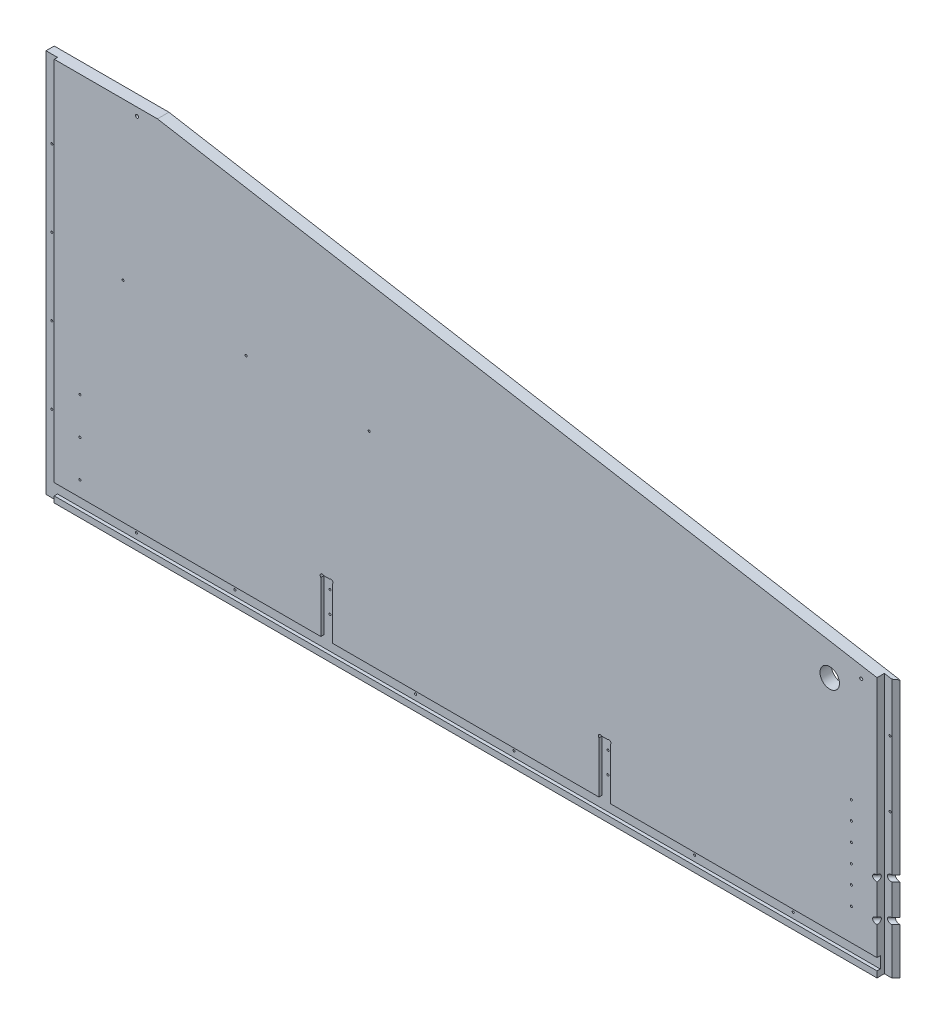
from build123d import *

# Parameters (mm, degrees)
CABSIDERIGHT_THICKNESS_DEPTH  = 17.78
LEDGECUTS_DEPTH_DEPTH         = 5.08
SKETCH9_R                     = 3.301999998
SKETCH9_R_2                   = 3.174999998
SKETCH9_R_3                   = 3.174999999
CUT_EXTRUDE4_DEPTH            = 5.08
SKETCH10_R                    = 15.08125
SKETCH10_R_2                  = 1.5875
CUT_EXTRUDE5_DEPTH            = 17.78
FRONTLEDGECUT_W               = 17.78
FRONTLEDGECUT_H               = 402.324113577
FRONTLEDGECUT_THICKNESS_DEPTH = 11.43
CUT_EXTRUDE8_DEPTH            = 594.36
SKETCH15_R                    = 2.38125
CUT_EXTRUDE9_DEPTH            = 17.78
SKETCH16_R                    = 1.5875
CUT_EXTRUDE10_DEPTH           = 12.7
SKETCH17_R                    = 4.7625
CUT_EXTRUDE11_DEPTH           = 76.2


with BuildPart() as part:
    # CabSideRight_Outline → CabSideRight_Thickness (new body)
    with BuildSketch(Plane.XY):
        Polygon((9092.234544556, -4658.6775), (10222.970833334, -4853.78125), (10222.970833334, -5253.0375), (8914.870833334, -5253.0375), (8914.870833334, -4658.6775), align=None)
    extrude(amount=-CABSIDERIGHT_THICKNESS_DEPTH)

    # CabSideRight_LedgeCuts → LedgeCuts_Depth (cut)
    with BuildSketch(Plane.XY):
        Polygon((8932.650833334, -4658.6775), (8914.870833334, -4658.6775), (8914.870833334, -5253.0375), (8932.650833334, -5253.0375), (8932.650833334, -5243.5125), (10222.970833334, -5243.5125), (10222.970833334, -5225.7325), (9792.864166668, -5225.7325), (9792.864166668, -5141.912499999), (9775.084166668, -5141.912499999), (9775.084166668, -5225.7325), (9362.757500002, -5225.7325), (9362.757500002, -5141.9125), (9344.977500002, -5141.912499999), (9344.977500002, -5225.7325), (8932.650833334, -5225.7325), align=None)
    extrude(amount=-LEDGECUTS_DEPTH_DEPTH, mode=Mode.SUBTRACT)

    # Sketch9 → Cut-Extrude4 (cut)
    with BuildSketch(Plane.XY):
        with Locations((9347.222564031, -5144.157564028)):
            Circle(SKETCH9_R)
        with Locations((9360.512435973, -5144.15756403)):
            Circle(SKETCH9_R_2)
        with Locations((9777.329230699, -5144.157564029)):
            Circle(SKETCH9_R_3)
        with Locations((9790.619102638, -5144.157564029)):
            Circle(SKETCH9_R_3)
    extrude(amount=-CUT_EXTRUDE4_DEPTH, mode=Mode.SUBTRACT)

    # Sketch10 → Cut-Extrude5 (cut)
    with BuildSketch(Plane.XY):
        with Locations((10132.081036572, -4887.549352662)):
            Circle(SKETCH10_R)
        with Locations((10165.516033334, -5148.2625)):
            Circle(SKETCH10_R_2)
        with Locations((8923.760833334, -4778.904166666)):
            Circle(SKETCH10_R_2)
        with Locations((8923.760833334, -4897.4375)):
            Circle(SKETCH10_R_2)
        with Locations((8923.760833334, -5015.970833334)):
            Circle(SKETCH10_R_2)
        with Locations((8923.760833334, -5134.504166666)):
            Circle(SKETCH10_R_2)
        with Locations((9054.570833334, -5234.6225)):
            Circle(SKETCH10_R_2)
        with Locations((9206.970833334, -5234.6225)):
            Circle(SKETCH10_R_2)
        with Locations((9353.8675, -5193.9825)):
            Circle(SKETCH10_R_2)
        with Locations((9353.8675, -5160.9625)):
            Circle(SKETCH10_R_2)
        with Locations((9486.370833334, -5234.6225)):
            Circle(SKETCH10_R_2)
        with Locations((9638.770833334, -5234.6225)):
            Circle(SKETCH10_R_2)
        with Locations((9783.974166666, -5193.9825)):
            Circle(SKETCH10_R_2)
        with Locations((9783.974166666, -5160.9625)):
            Circle(SKETCH10_R_2)
        with Locations((9918.170833334, -5234.6225)):
            Circle(SKETCH10_R_2)
        with Locations((10070.570833334, -5234.6225)):
            Circle(SKETCH10_R_2)
        with Locations((10214.080833334, -5031.58125)):
            Circle(SKETCH10_R_2)
        with Locations((10214.080833334, -4929.98125)):
            Circle(SKETCH10_R_2)
        with Locations((10165.516033334, -5091.1125)):
            Circle(SKETCH10_R_2)
        with Locations((8972.338333334, -5087.9375)):
            Circle(SKETCH10_R_2)
        with Locations((8972.338333334, -5145.0875)):
            Circle(SKETCH10_R_2)
        with Locations((8972.338333334, -5202.2375)):
            Circle(SKETCH10_R_2)
        with Locations((10165.503333334, -5176.8375)):
            Circle(SKETCH10_R_2)
        with Locations((10165.503333334, -5119.6875)):
            Circle(SKETCH10_R_2)
        with Locations((10165.503333334, -5062.5375)):
            Circle(SKETCH10_R_2)
        with Locations((10165.516033334, -5033.9625)):
            Circle(SKETCH10_R_2)
    extrude(amount=-CUT_EXTRUDE5_DEPTH, mode=Mode.SUBTRACT)

    # FrontLedgeCut → FrontLedgeCut_Thickness (cut)
    with BuildSketch(Plane.XY):
        with Locations((10214.080833334, -5051.875443212)):
            Rectangle(FRONTLEDGECUT_W, FRONTLEDGECUT_H)
    extrude(amount=-FRONTLEDGECUT_THICKNESS_DEPTH, mode=Mode.SUBTRACT)

    # FrontBevelAngleCut → Cut-Extrude8 (cut)
    with BuildSketch(Plane.XZ.offset(5253.0375)):
        Polygon((10222.970833334, -11.43), (10229.320833334, -11.43), (10222.970833334, -17.78), (10216.620833334, -11.43), align=None)
    extrude(amount=-CUT_EXTRUDE8_DEPTH, mode=Mode.SUBTRACT)

    # Sketch15 → Cut-Extrude9 (cut)
    with BuildSketch(Plane(origin=(0, 0, -17.78), x_dir=(-1, 0, 0), z_dir=(0, 0, -1))):
        with Locations((-10180.810459726, -4864.401180469)):
            Circle(SKETCH15_R)
        with Locations((-9060.71197776, -4671.132938908)):
            Circle(SKETCH15_R)
    extrude(amount=-CUT_EXTRUDE9_DEPTH, mode=Mode.SUBTRACT)

    # Sketch16 → Cut-Extrude10 (cut)
    with BuildSketch(Plane.XY):
        with Locations((9038.992342664, -4901.492108659)):
            Circle(SKETCH16_R)
        with Locations((9229.403491719, -4907.309695425)):
            Circle(SKETCH16_R)
        with Locations((9419.814640773, -4913.127282192)):
            Circle(SKETCH16_R)
    extrude(amount=-CUT_EXTRUDE10_DEPTH, mode=Mode.SUBTRACT)

    # Sketch17 → Cut-Extrude11 (cut)
    with BuildSketch(Plane(origin=(5086.511865443, 0, -5086.511865443), x_dir=(0.707106781, 0, 0.707106781), z_dir=(-0.707106781, 0, 0.707106781))):
        with Locations((7216.159641553, -5119.6875)):
            Circle(SKETCH17_R)
        with Locations((7216.159641553, -5176.8375)):
            Circle(SKETCH17_R)
    extrude(amount=-CUT_EXTRUDE11_DEPTH, mode=Mode.SUBTRACT)


solid = part.part
